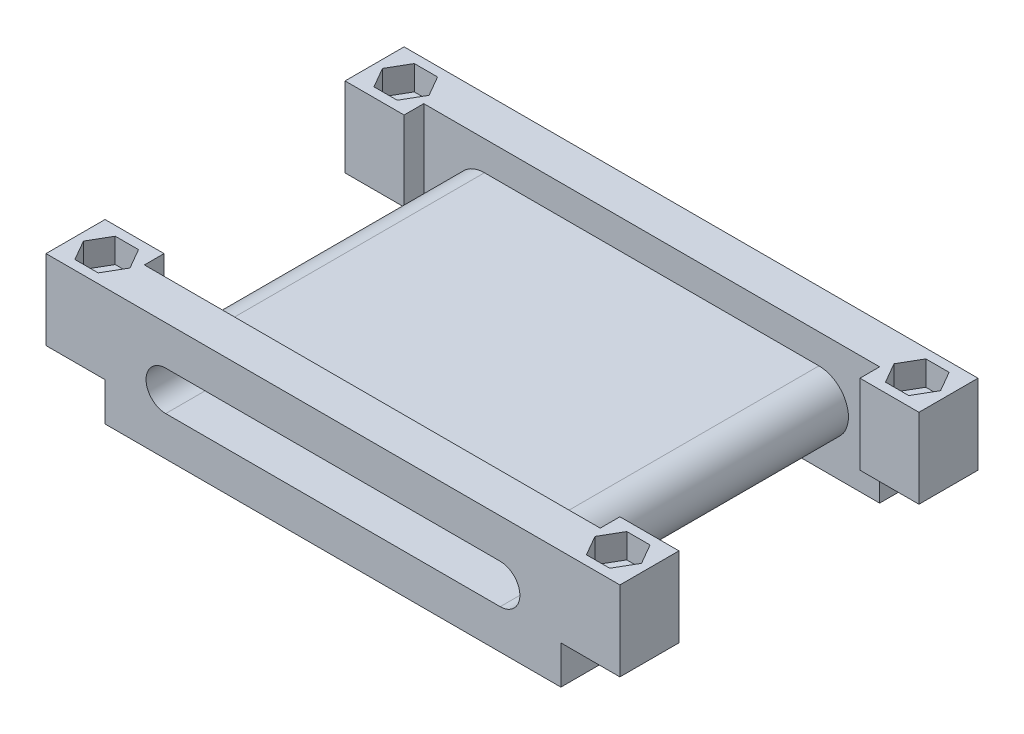
from build123d import *

# Parameters (mm, degrees)
ESBO_O1_W                 = 58
ESBO_O1_H                 = 6
RESSALTO_EXTRUS_O1_DEPTH  = 8.6
ESBO_O2_W                 = 47.9
ESBO_O2_H                 = 6
RESSALTO_EXTRUS_O2_DEPTH  = 3.4
CORTE_EXTRUS_O2_DEPTH     = 7
ESBO_O8_W                 = 5.05
ESBO_O8_H                 = 6
CORTE_EXTRUS_O3_DEPTH     = 0.5
ESBO_O9_W                 = 46
ESBO_O9_H                 = 2
CORTE_EXTRUS_O4_DEPTH     = 8.1
ESBO_O10_W                = 47.9
ESBO_O10_H                = 2
CORTE_EXTRUS_O5_DEPTH     = 3.9
ESBO_O11_W                = 0.95
ESBO_O11_H                = 4
CORTE_EXTRUS_O6_DEPTH     = 4.9
ESBO_O15_W                = 4
ESBO_O15_H                = 3.9
RESSALTO_EXTRUS_O4_DEPTH  = 0.17
ESBO_O16_R                = 1
CORTE_EXTRUS_O9_DEPTH     = 2.5
ESBO_O16_4_R              = 1
CORTE_EXTRUS_O10_DEPTH    = 13
RESSALTO_EXTRUS_O5_DEPTH  = 14.2
ESBO_O18_W                = 2
ESBO_O18_H                = 8.1
CORTE_EXTRUS_O11_DEPTH    = 0.17
ESBO_O19_W                = 2
ESBO_O19_H                = 8.1
CORTE_EXTRUS_O12_DEPTH    = 0.17
ESBO_O20_W                = 4
ESBO_O20_H                = 3.9
RESSALTO_EXTRUS_O6_DEPTH  = 0.17
ESBO_O23_W                = 6
ESBO_O23_H                = 8.1
RESSALTO_EXTRUS_O9_DEPTH  = 0.17
ESBO_O24_W                = 6
ESBO_O24_H                = 8.1
RESSALTO_EXTRUS_O10_DEPTH = 0.17


with BuildPart() as part:
    # Esboço1 → Ressalto-extrusão1 (new body)
    with BuildSketch(Plane(origin=(0, 0, 0), x_dir=(1, 0, 0), z_dir=(0, 1, 0))):
        Rectangle(ESBO_O1_W, ESBO_O1_H)
    extrude(amount=RESSALTO_EXTRUS_O1_DEPTH)

    # Esboço2 → Ressalto-extrusão2 (add)
    with BuildSketch(Plane.XZ):
        Rectangle(ESBO_O2_W, ESBO_O2_H)
    extrude(amount=RESSALTO_EXTRUS_O2_DEPTH)

    # Esboço4 → Corte-extrusão2 (cut, through all)
    with BuildSketch(Plane.XY.offset(3)):
        with BuildLine():
            Line((-17, 4.6), (17, 4.6))
            ThreePointArc((17, 4.6), (19, 2.6), (17, 0.6))
            Line((17, 0.6), (-17, 0.6))
            ThreePointArc((-17, 0.6), (-19, 2.6), (-17, 4.6))
        make_face()
    extrude(amount=-CORTE_EXTRUS_O2_DEPTH, mode=Mode.SUBTRACT)


with BuildPart() as body_2:
    # Espelhar1: mirrored copy
    add(part.part.mirror(Plane(origin=(-29, 8.6, 3), x_dir=(1, 0, 0), z_dir=(0, 0, -1))))

    # Esboço8 → Corte-extrusão3 (cut)
    with BuildSketch(Plane.XZ):
        with Locations((-26.475, 6)):
            Rectangle(ESBO_O8_W, ESBO_O8_H)
        with Locations((26.475, 6)):
            Rectangle(ESBO_O8_W, ESBO_O8_H)
    extrude(amount=-CORTE_EXTRUS_O3_DEPTH, mode=Mode.SUBTRACT)

    # Esboço9 → Corte-extrusão4 (cut)
    with BuildSketch(Plane(origin=(0, 8.6, 0), x_dir=(1, 0, 0), z_dir=(0, 1, 0))):
        with Locations((0, -4)):
            Rectangle(ESBO_O9_W, ESBO_O9_H)
    extrude(amount=-CORTE_EXTRUS_O4_DEPTH, mode=Mode.SUBTRACT)

    # Esboço10 → Corte-extrusão5 (cut)
    with BuildSketch(Plane.XZ.offset(3.4)):
        with Locations((0, 4)):
            Rectangle(ESBO_O10_W, ESBO_O10_H)
    extrude(amount=-CORTE_EXTRUS_O5_DEPTH, mode=Mode.SUBTRACT)

    # Esboço11 → Corte-extrusão6 (cut, through all)
    with BuildSketch(Plane.XZ.offset(-0.5)):
        with Locations((23.475, 7)):
            Rectangle(ESBO_O11_W, ESBO_O11_H)
        with Locations((-23.475, 7)):
            Rectangle(ESBO_O11_W, ESBO_O11_H)
    extrude(amount=CORTE_EXTRUS_O6_DEPTH, mode=Mode.SUBTRACT)

    # Esboço15 → Ressalto-extrusão4 (add)
    with BuildSketch(Plane.ZY.offset(23)):
        with Locations((7, -1.45)):
            Rectangle(ESBO_O15_W, ESBO_O15_H)
    extrude(amount=RESSALTO_EXTRUS_O4_DEPTH)

    # Esboço16 → Corte-extrusão9 (cut)
    with BuildSketch(Plane(origin=(0, 8.6, 0), x_dir=(1, 0, 0), z_dir=(0, 1, 0))):
        with Locations((26, -6)):
            Circle(ESBO_O16_R)
        Polygon((27.183568052, -3.95), (24.816431948, -3.95), (23.632863896, -6), (24.816431948, -8.05), (27.183568052, -8.05), (28.367136104, -6), align=None)
        with Locations((26, -6)):
            Circle(ESBO_O16_R, mode=Mode.SUBTRACT)
        Polygon((-24.816431948, -3.95), (-27.183568052, -3.95), (-28.367136104, -6), (-27.183568052, -8.05), (-24.816431948, -8.05), (-23.632863896, -6), align=None)
        with Locations((-26, -6)):
            Circle(ESBO_O16_R, mode=Mode.SUBTRACT)
        with Locations((-26, -6)):
            Circle(ESBO_O16_R)
    extrude(amount=-CORTE_EXTRUS_O9_DEPTH, mode=Mode.SUBTRACT)

    # Esboço16<4> → Corte-extrusão10 (cut, through all)
    with BuildSketch(Plane(origin=(0, 8.6, 0), x_dir=(1, 0, 0), z_dir=(0, 1, 0))):
        with Locations((26, -6)):
            Circle(ESBO_O16_4_R)
        with Locations((-26, -6)):
            Circle(ESBO_O16_4_R)
    extrude(amount=-CORTE_EXTRUS_O10_DEPTH, mode=Mode.SUBTRACT)

    # Esboço17 → Ressalto-extrusão5 (add)
    with BuildSketch(Plane(origin=(0, 0, 5), x_dir=(-1, 0, 0), z_dir=(0, 0, -1))):
        with BuildLine():
            Line((17, 5.6), (-17, 5.6))
            ThreePointArc((-17, 5.6), (-20, 2.6), (-17, -0.4))
            Line((-17, -0.4), (17, -0.4))
            ThreePointArc((17, -0.4), (20, 2.6), (17, 5.6))
        make_face()
        with BuildLine():
            Line((-17, 0.6), (17, 0.6))
            ThreePointArc((17, 0.6), (19, 2.6), (17, 4.6))
            Line((17, 4.6), (-17, 4.6))
            ThreePointArc((-17, 4.6), (-19, 2.6), (-17, 0.6))
        make_face(mode=Mode.SUBTRACT)
    extrude(amount=RESSALTO_EXTRUS_O5_DEPTH)

    # Esboço18 → Corte-extrusão11 (cut)
    with BuildSketch(Plane(origin=(-23, 0, 0), x_dir=(0, 0, -1), z_dir=(1, 0, 0))):
        with Locations((-4, 4.55)):
            Rectangle(ESBO_O18_W, ESBO_O18_H)
    extrude(amount=-CORTE_EXTRUS_O11_DEPTH, mode=Mode.SUBTRACT)

    # Esboço19 → Corte-extrusão12 (cut)
    with BuildSketch(Plane.ZY.offset(-23)):
        with Locations((4, 4.55)):
            Rectangle(ESBO_O19_W, ESBO_O19_H)
    extrude(amount=-CORTE_EXTRUS_O12_DEPTH, mode=Mode.SUBTRACT)

    # Esboço20 → Ressalto-extrusão6 (add)
    with BuildSketch(Plane(origin=(23, 0, 0), x_dir=(0, 0, -1), z_dir=(1, 0, 0))):
        with Locations((-7, -1.45)):
            Rectangle(ESBO_O20_W, ESBO_O20_H)
    extrude(amount=RESSALTO_EXTRUS_O6_DEPTH)

    # Esboço23 → Ressalto-extrusão9 (add)
    with BuildSketch(Plane.ZY.offset(29)):
        with Locations((6, 4.55)):
            Rectangle(ESBO_O23_W, ESBO_O23_H)
    extrude(amount=RESSALTO_EXTRUS_O9_DEPTH)

    # Esboço24 → Ressalto-extrusão10 (add)
    with BuildSketch(Plane(origin=(29, 0, 0), x_dir=(0, 0, -1), z_dir=(1, 0, 0))):
        with Locations((-6, 4.55)):
            Rectangle(ESBO_O24_W, ESBO_O24_H)
    extrude(amount=RESSALTO_EXTRUS_O10_DEPTH)

    # Espelhar2: body 2 across plane


with BuildPart() as body_2_1:
    add(body_2.part)
    add(body_2.part.mirror(Plane(origin=(-17, 2.6, -9.2), x_dir=(1, 0, 0), z_dir=(0, 0, -1))))


solid = body_2_1.part
